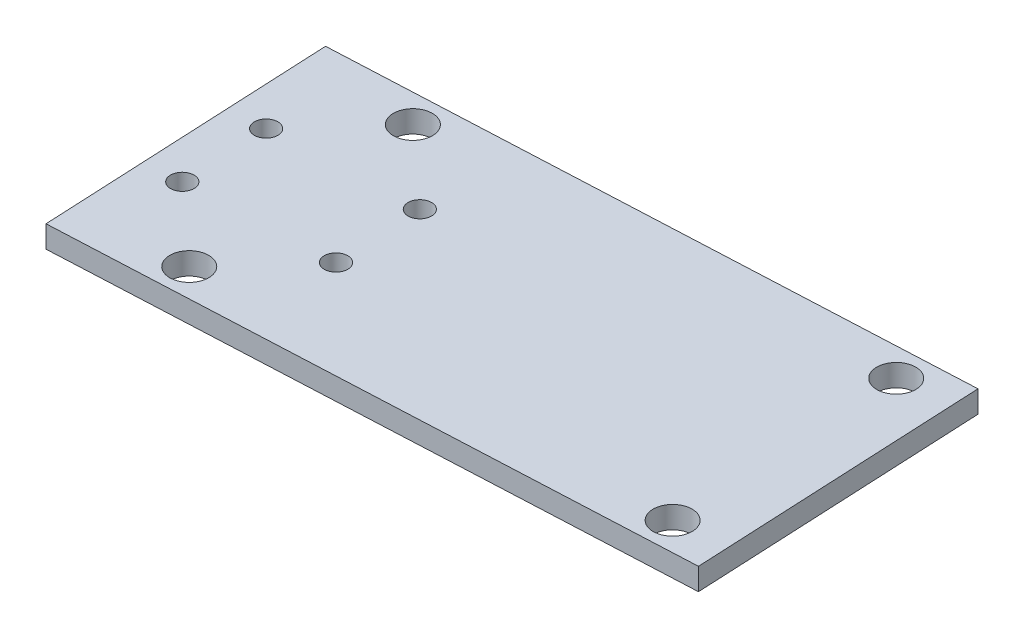
from build123d import *

# Parameters (mm, degrees)
SKETCH_1_R      = 2.65
SKETCH_1_R_2    = 1.6
EXTRUDE_1_DEPTH = 3


with BuildPart() as part:
    # 草图1 → 凸台-拉伸1 (new body)
    with BuildSketch(Plane(origin=(0, 0, 0), x_dir=(1, 0, 0), z_dir=(0, 1, 0))):
        Polygon((-15.222569187, 19.831121687), (14.743614759, 21.25513704), (69.57570845, 23.860798923), (71.474395588, -16.094113005), (16.642301897, -18.699774888), (-13.323882049, -20.123790241), align=None)
        with Locations((-0.0496085, 16.547638171)):
            Circle(SKETCH_1_R, mode=Mode.SUBTRACT)
        with Locations((1.46934121, -15.416291372)):
            Circle(SKETCH_1_R, mode=Mode.SUBTRACT)
        with Locations((-8.994058556, -5.902235174)):
            Circle(SKETCH_1_R_2, mode=Mode.SUBTRACT)
        with Locations((-9.563664698, 6.084238404)):
            Circle(SKETCH_1_R_2, mode=Mode.SUBTRACT)
        with Locations((10.413791266, 7.033581973)):
            Circle(SKETCH_1_R_2, mode=Mode.SUBTRACT)
        with Locations((10.983397408, -4.952891605)):
            Circle(SKETCH_1_R_2, mode=Mode.SUBTRACT)
        with Locations((62.773467577, 19.533037481)):
            Circle(SKETCH_1_R, mode=Mode.SUBTRACT)
        with Locations((64.292417287, -12.430892061)):
            Circle(SKETCH_1_R, mode=Mode.SUBTRACT)
    extrude(amount=EXTRUDE_1_DEPTH)


solid = part.part
